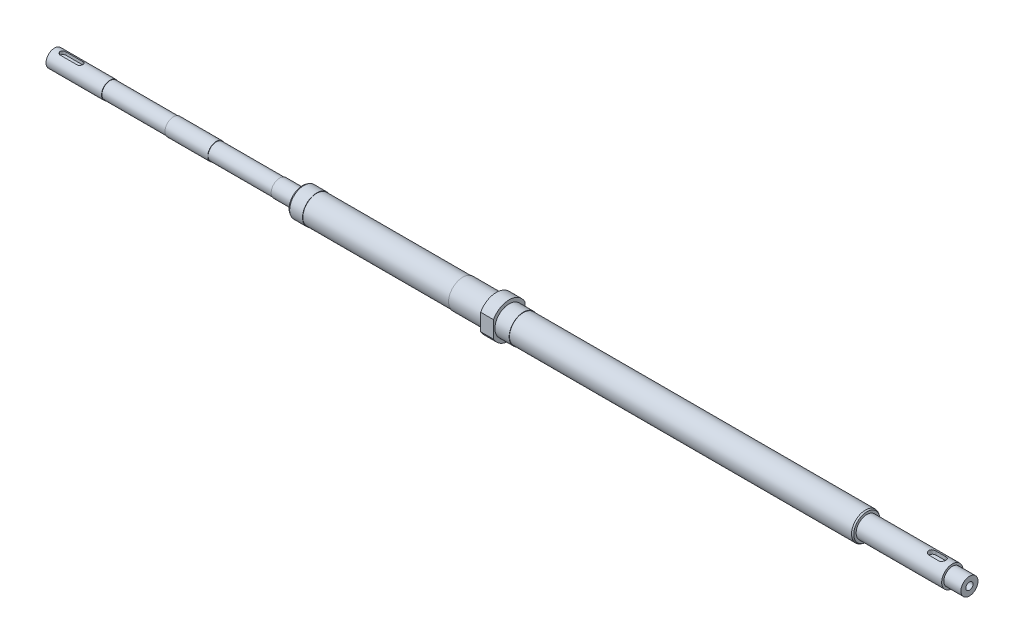
from build123d import *

# Parameters (mm, degrees)
ODEBRAT_VYSUNUT_M1_DEPTH = 2.4
ODEBRAT_VYSUNUT_M2_DEPTH = 2.9
SKICA4_W                 = 43.201709197
SKICA4_H                 = 57.022390215
SKICA4_W_2               = 28.704491345
SKICA4_H_2               = 62.531332999
ODEBRAT_VYSUNUT_M3_DEPTH = 320.0000001
M6_Z_VIT1_D              = 5
M6_Z_VIT1_DEPTH          = 22
M6_Z_VIT1_TIP            = 1.502151548
M5_Z_VIT1_D              = 4.2
M5_Z_VIT1_DEPTH          = 20
M5_Z_VIT1_TIP            = 1.2618073
ZKOSEN_1_SIZE            = 1
ZKOSEN_1_SIZE2           = 0.577350269
ZKOSEN_1_PART_2_SIZE     = 1
ZKOSEN_1_PART_2_SIZE2    = 0.577350269


with BuildPart() as part:
    # Skica1 → Rotovat1 (revolve)
    with BuildSketch(Plane.XY, mode=Mode.PRIVATE) as rotovat1_sk:
        Polygon((0, 0), (0, 6), (39, 6), (39, 5.75), (83.5, 5.75), (83.5, 6), (113.5, 6), (113.5, 5.75), (158, 5.75), (158, 6), (174, 6), (174, 10), (184, 10), (184, 9.75), (286.5, 9.75), (286.5, 10), (310, 10), (310, 12.5), (319, 12.5), (319, 10), (329, 10), (329, 9.75), (570, 9.75), (570, 7.5), (630, 7.5), (630, 6), (642, 6), (642, 0), align=None)
    revolve(rotovat1_sk.sketch.rotate(Axis((-5427.299905209, 0, 0), (1, 0, 0)), 180), axis=Axis((-5427.299905209, 0, 0), (1, 0, 0)))  # turned: the seam where the file's is

    # Skica2 → Odebrat vysunutím1 (cut)
    with BuildSketch(Plane(origin=(0, 6, 0), x_dir=(1, 0, 0), z_dir=(0, 1, 0))):
        with BuildLine():
            Line((6, 2), (18, 2))
            ThreePointArc((18, 2), (20, 0), (18, -2))
            Line((18, -2), (6, -2))
            ThreePointArc((6, -2), (4, 0), (6, 2))
        make_face()
    extrude(amount=-ODEBRAT_VYSUNUT_M1_DEPTH, mode=Mode.SUBTRACT)

    # Skica3 → Odebrat vysunutím2 (cut)
    with BuildSketch(Plane(origin=(0, 7.5, 0), x_dir=(1, 0, 0), z_dir=(0, 1, 0))):
        with BuildLine():
            Line((616, 2.5), (623, 2.5))
            ThreePointArc((623, 2.5), (625.5, 0), (623, -2.5))
            Line((623, -2.5), (616, -2.5))
            ThreePointArc((616, -2.5), (613.5, 0), (616, 2.5))
        make_face()
    extrude(amount=-ODEBRAT_VYSUNUT_M2_DEPTH, mode=Mode.SUBTRACT)

    # Skica4 → Odebrat vysunutím3 (cut, through all)
    with BuildSketch(Plane(origin=(319, 0, 0), x_dir=(0, 0, -1), z_dir=(1, 0, 0))):
        with Locations((-32.600854599, -5.674005363)):
            Rectangle(SKICA4_W, SKICA4_H)
        with Locations((25.352245673, -4.175959518)):
            Rectangle(SKICA4_W_2, SKICA4_H_2)
    extrude(amount=-ODEBRAT_VYSUNUT_M3_DEPTH, mode=Mode.SUBTRACT)

    # M6 závit1
    with Locations(Plane(origin=(642, 0, 0), x_dir=(0, 0, -1), z_dir=(1, 0, 0))):
        with Locations((0, 0)):
            Hole(M6_Z_VIT1_D / 2, depth=M6_Z_VIT1_DEPTH)
            with Locations((0, 0, -(M6_Z_VIT1_DEPTH + M6_Z_VIT1_TIP / 2))):  # 118° drill point
                Cone(0, M6_Z_VIT1_D / 2, M6_Z_VIT1_TIP, mode=Mode.SUBTRACT)

    # M5 závit1
    with Locations(Plane.ZY):
        with Locations((0, 0)):
            Hole(M5_Z_VIT1_D / 2, depth=M5_Z_VIT1_DEPTH)
            with Locations((0, 0, -(M5_Z_VIT1_DEPTH + M5_Z_VIT1_TIP / 2))):  # 118° drill point
                Cone(0, M5_Z_VIT1_D / 2, M5_Z_VIT1_TIP, mode=Mode.SUBTRACT)

    # Zkosení1
    zkosen_1_edges = [part.edges().sort_by_distance(p)[0] for p in [
        (570, 9.75, 0),
    ]]
    zkosen_1_side = [part.faces().sort_by_distance(p)[0] for p in [
        (449.5, 9.75, 0),
    ]]
    chamfer(zkosen_1_edges, length=ZKOSEN_1_SIZE, length2=ZKOSEN_1_SIZE2, reference=zkosen_1_side[0])

    # Zkosení1 part 2
    zkosen_1_part_2_edges = [part.edges().sort_by_distance(p)[0] for p in [
        (174, 10, 0),
    ]]
    zkosen_1_part_2_side = [part.faces().sort_by_distance(p)[0] for p in [
        (179, 10, 0),
    ]]
    chamfer(zkosen_1_part_2_edges, length=ZKOSEN_1_PART_2_SIZE, length2=ZKOSEN_1_PART_2_SIZE2, reference=zkosen_1_part_2_side[0])


solid = part.part
